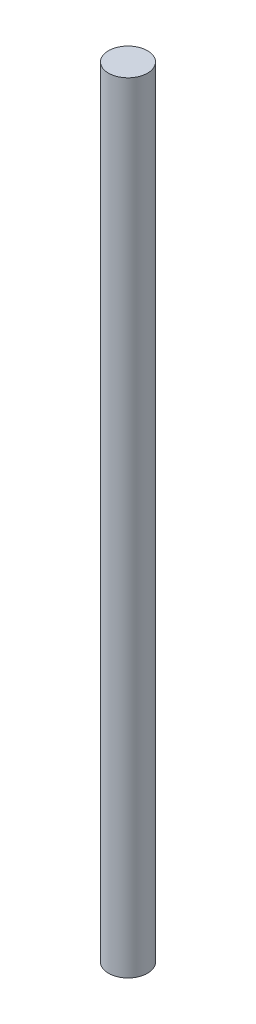
from build123d import *

# Parameters (mm, degrees)
SKETCH1_R           = 3.175
BOSS_EXTRUDE1_DEPTH = 127


with BuildPart() as part:
    # Sketch1 → Boss-Extrude1 (new body)
    with BuildSketch(Plane(origin=(0, 0, 0), x_dir=(1, 0, 0), z_dir=(0, 1, 0))):
        Circle(SKETCH1_R)
    extrude(amount=BOSS_EXTRUDE1_DEPTH)


solid = part.part
